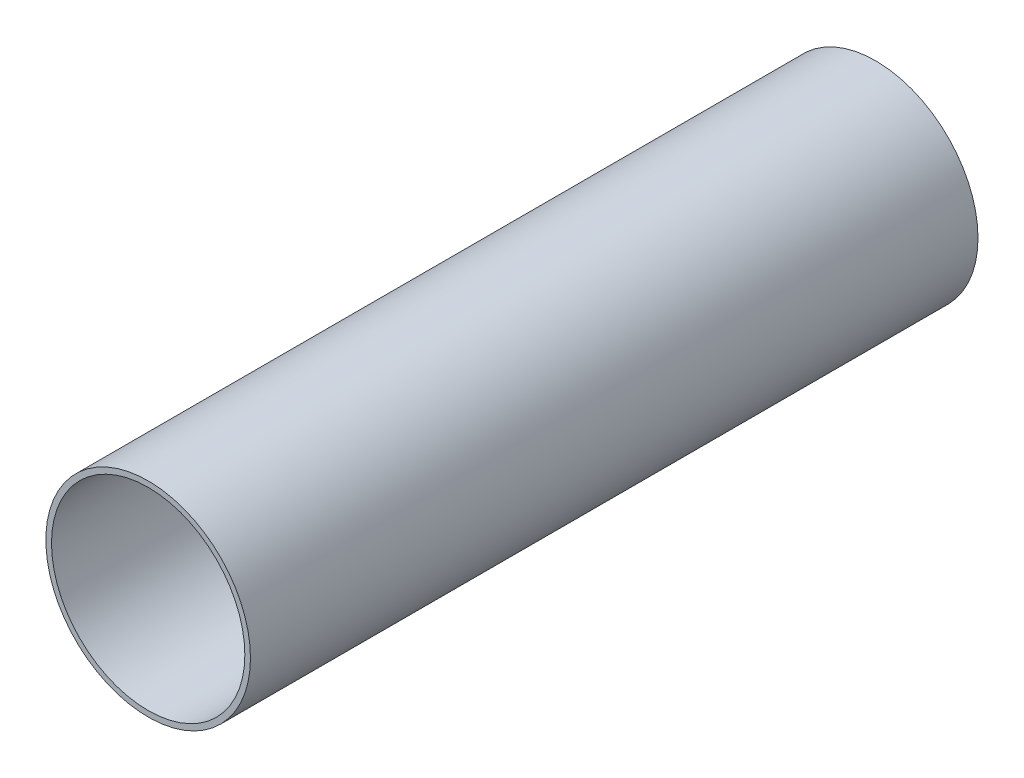
from build123d import *

# Parameters (mm, degrees)
SKETCH1_R           = 28.575
SKETCH1_R_2         = 27.0002
BOSS_EXTRUDE1_DEPTH = 101.6


with BuildPart() as part:
    # Sketch1 → Boss-Extrude1 (new body, symmetric)
    with BuildSketch(Plane.XY):
        Circle(SKETCH1_R)
        Circle(SKETCH1_R_2, mode=Mode.SUBTRACT)
    extrude(amount=BOSS_EXTRUDE1_DEPTH, both=True)


solid = part.part
